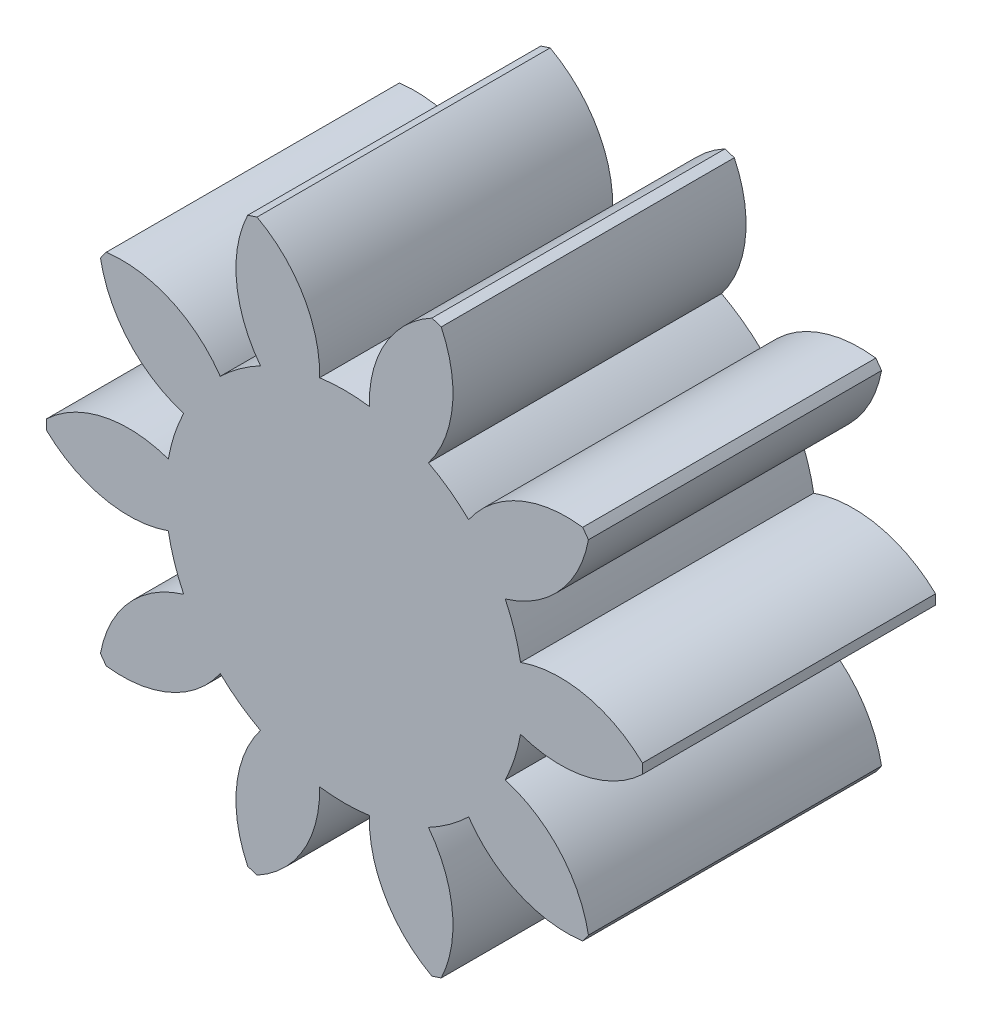
from build123d import *

# Parameters (mm, degrees)
SKETCH1_R           = 15
BOSS_EXTRUDE1_DEPTH = 14.75
CUT_EXTRUDE1_DEPTH  = 15.75
CIRPATTERN1_COUNT   = 10


with BuildPart() as part:
    # Sketch1 → Boss-Extrude1 (new body)
    with BuildSketch(Plane.XY):
        Circle(SKETCH1_R)
    extrude(amount=BOSS_EXTRUDE1_DEPTH)

    # Sketch2 → Cut-Extrude1 (cut, through all)
    with BuildSketch(Plane.XY.offset(14.75)):
        with BuildLine():
            ThreePointArc((-1.25, 8.912771735), (0, 9), (1.25, 8.912771735))
            ThreePointArc((1.25, 8.912771735), (2.05890341, 12.07109765), (4.4, 14.340153416))
            ThreePointArc((4.4, 14.340153416), (0, 15), (-4.4, 14.340153416))
            ThreePointArc((-4.4, 14.340153416), (-2.05890341, 12.07109765), (-1.25, 8.912771735))
        make_face()
    cut_extrude1 = extrude(amount=-CUT_EXTRUDE1_DEPTH, mode=Mode.SUBTRACT)

    # CirPattern1: Cut-Extrude1 ×10 about axis
    cirpattern1_axis = Axis((0, 0, 0), (0, 0, 1))
    for i in range(1, CIRPATTERN1_COUNT):
        add(cut_extrude1.rotate(cirpattern1_axis, i * 360 / CIRPATTERN1_COUNT), mode=Mode.SUBTRACT)


solid = part.part
